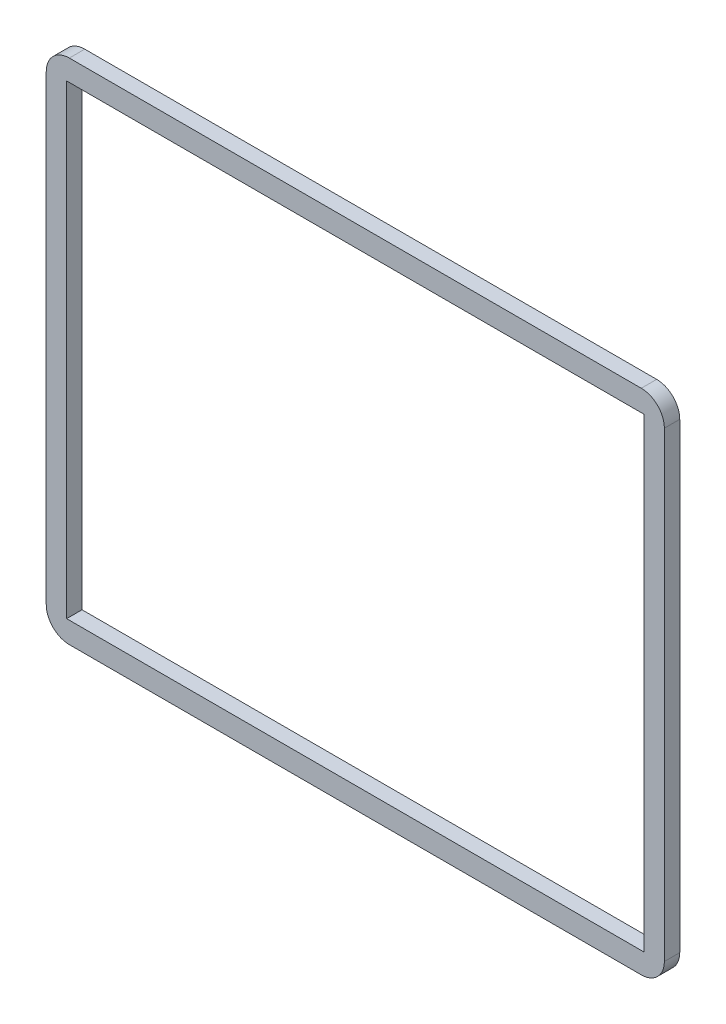
from build123d import *

# Parameters (mm, degrees)
SKETCH1_W                  = 80.3
SKETCH1_H                  = 66
BOSS_EXTRUDE1_DEPTH        = 2
F_3_2_3_2_DIAMETER_HOLE1_D = 3.2
FILLET1_R                  = 3
SKETCH4_W                  = 75
SKETCH4_H                  = 60.5
CUT_EXTRUDE1_DEPTH         = 3


with BuildPart() as part:
    # Sketch1 → Boss-Extrude1 (new body)
    with BuildSketch(Plane.XY):
        with Locations((40.15, 33)):
            Rectangle(SKETCH1_W, SKETCH1_H)
    extrude(amount=BOSS_EXTRUDE1_DEPTH)

    # Ø3.2 (3.2) Diameter Hole1 (through all)
    with Locations(Plane.XY.offset(2)):
        with Locations((7, 59), (73.3, 59), (73.3, 7), (7, 7)):
            Hole(F_3_2_3_2_DIAMETER_HOLE1_D / 2)

    # Fillet1
    fillet1_edges = [part.edges().sort_by_distance(p)[0] for p in [
        (0, 66, 1),
        (80.3, 66, 1),
        (80.3, 0, 1),
        (0, 0, 1),
    ]]
    fillet(fillet1_edges, radius=FILLET1_R)

    # Sketch4 → Cut-Extrude1 (cut, through all)
    with BuildSketch(Plane.XY.offset(2)):
        with Locations((40.15, 33)):
            Rectangle(SKETCH4_W, SKETCH4_H)
    extrude(amount=-CUT_EXTRUDE1_DEPTH, mode=Mode.SUBTRACT)


solid = part.part
